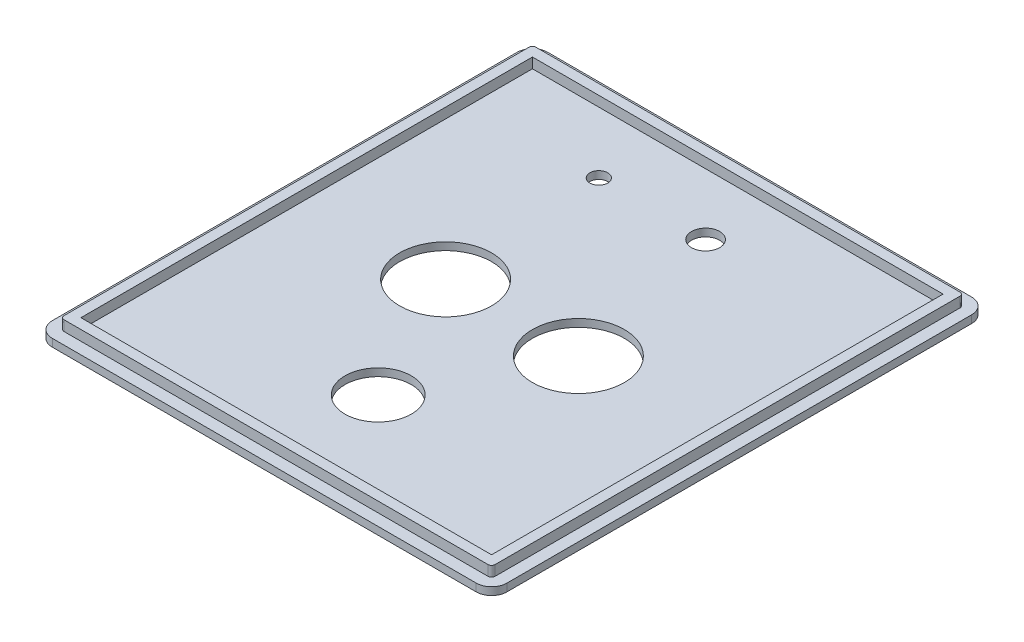
from build123d import *

# Parameters (mm, degrees)
BOSS_EXTRUDE1_DEPTH = 1.5
BOSS_EXTRUDE2_DEPTH = 2
SKETCH3_W           = 80.4
SKETCH3_H           = 88.4
CUT_EXTRUDE1_DEPTH  = 2
SKETCH4_R           = 9
CUT_EXTRUDE2_DEPTH  = 2
SKETCH5_R           = 1.75
SKETCH5_R_2         = 2.75
CUT_EXTRUDE3_DEPTH  = 2
SKETCH6_R           = 6.5
CUT_EXTRUDE4_DEPTH  = 2


with BuildPart() as part:
    # Sketch1 → Boss-Extrude1 (new body)
    with BuildSketch(Plane(origin=(0, 0, 0), x_dir=(1, 0, 0), z_dir=(0, 1, 0))):
        with BuildLine():
            Line((3, 0), (86, 0))
            ThreePointArc((86, 0), (88.121320344, 0.878679656), (89, 3))
            Line((89, 3), (89, 94))
            ThreePointArc((89, 94), (88.121320344, 96.121320344), (86, 97))
            Line((86, 97), (3, 97))
            ThreePointArc((3, 97), (0.878679656, 96.121320344), (0, 94))
            Line((0, 94), (0, 3))
            ThreePointArc((0, 3), (0.878679656, 0.878679656), (3, 0))
        make_face()
    extrude(amount=BOSS_EXTRUDE1_DEPTH)

    # Sketch2 → Boss-Extrude2 (add)
    with BuildSketch(Plane(origin=(0, 1.5, 0), x_dir=(1, 0, 0), z_dir=(0, 1, 0))):
        with BuildLine():
            Line((2.3, 94), (2.3, 3))
            ThreePointArc((2.3, 3), (2.505025253, 2.505025253), (3, 2.3))
            Line((3, 2.3), (86, 2.3))
            ThreePointArc((86, 2.3), (86.494974747, 2.505025253), (86.7, 3))
            Line((86.7, 3), (86.7, 94))
            ThreePointArc((86.7, 94), (86.494974747, 94.494974747), (86, 94.7))
            Line((86, 94.7), (3, 94.7))
            ThreePointArc((3, 94.7), (2.505025253, 94.494974747), (2.3, 94))
        make_face()
    extrude(amount=BOSS_EXTRUDE2_DEPTH)

    # Sketch3 → Cut-Extrude1 (cut)
    with BuildSketch(Plane(origin=(0, 3.5, 0), x_dir=(1, 0, 0), z_dir=(0, 1, 0))):
        with Locations((44.5, 48.5)):
            Rectangle(SKETCH3_W, SKETCH3_H)
    extrude(amount=-CUT_EXTRUDE1_DEPTH, mode=Mode.SUBTRACT)

    # Sketch4 → Cut-Extrude2 (cut)
    with BuildSketch(Plane(origin=(0, 1.5, 0), x_dir=(1, 0, 0), z_dir=(0, 1, 0))):
        with Locations((31.5, 48.5)):
            Circle(SKETCH4_R)
        with Locations((57.5, 48.5)):
            Circle(SKETCH4_R)
    extrude(amount=-CUT_EXTRUDE2_DEPTH, mode=Mode.SUBTRACT)

    # Sketch5 → Cut-Extrude3 (cut)
    with BuildSketch(Plane(origin=(0, 1.5, 0), x_dir=(1, 0, 0), z_dir=(0, 1, 0))):
        with Locations((29.3, 80.7)):
            Circle(SKETCH5_R)
        with Locations((50.2, 80.7)):
            Circle(SKETCH5_R_2)
    extrude(amount=-CUT_EXTRUDE3_DEPTH, mode=Mode.SUBTRACT)

    # Sketch6 → Cut-Extrude4 (cut)
    with BuildSketch(Plane(origin=(0, 1.5, 0), x_dir=(1, 0, 0), z_dir=(0, 1, 0))):
        with Locations((44.5, 22.3)):
            Circle(SKETCH6_R)
    extrude(amount=-CUT_EXTRUDE4_DEPTH, mode=Mode.SUBTRACT)


solid = part.part
